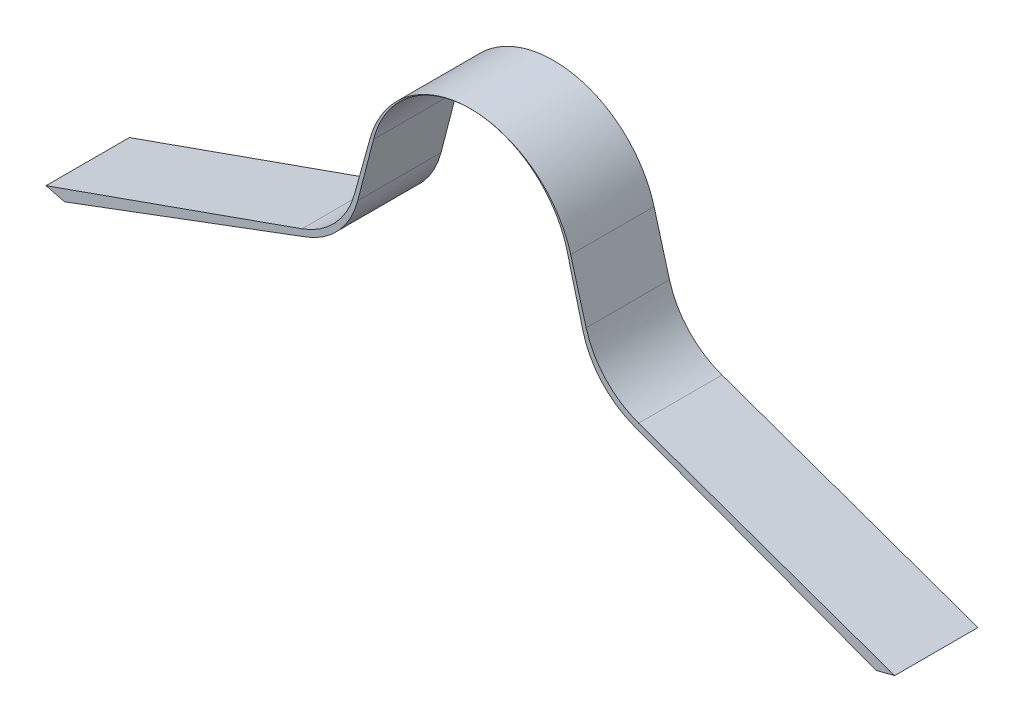
from build123d import *

# Parameters (mm, degrees)
EXTRUDE_1_DEPTH = 1


with BuildPart() as part:
    # Эскиз1 → Бобышка-Вытянуть1 (new body)
    with BuildSketch(Plane.XY):
        with BuildLine():
            Line((-4.86843377, -1.122994966), (-1.96901481, -0.038946637))
            ThreePointArc((-1.96901481, -0.038946637), (-1.576077366, 0.228594946), (-1.351074551, 0.647345548))
            Line((-1.351074551, 0.647345548), (-1.161777168, 1.379304216))
            ThreePointArc((-1.161777168, 1.379304216), (0, 2.278848211), (1.161777168, 1.379304216))
            Line((1.161777168, 1.379304216), (1.351074551, 0.647345548))
            ThreePointArc((1.351074551, 0.647345548), (1.576077366, 0.228594946), (1.96901481, -0.038946637))
            Line((1.96901481, -0.038946637), (4.86843377, -1.122994966))
            Line((4.86843377, -1.122994966), (5.091258523, -1.066440451))
            Line((5.091258523, -1.066440451), (2.019370682, 0.021372087))
            ThreePointArc((2.019370682, 0.021372087), (1.621823839, 0.282015218), (1.389547088, 0.696775202))
            Line((1.389547088, 0.696775202), (1.204538067, 1.363896181))
            ThreePointArc((1.204538067, 1.363896181), (0, 2.279848211), (-1.204538067, 1.363896181))
            Line((-1.204538067, 1.363896181), (-1.389547088, 0.696775202))
            ThreePointArc((-1.389547088, 0.696775202), (-1.621823839, 0.282015218), (-2.019370682, 0.021372087))
            Line((-2.019370682, 0.021372087), (-5.091258523, -1.066440451))
            Line((-5.091258523, -1.066440451), (-4.86843377, -1.122994966))
        make_face()
    extrude(amount=EXTRUDE_1_DEPTH)


solid = part.part
